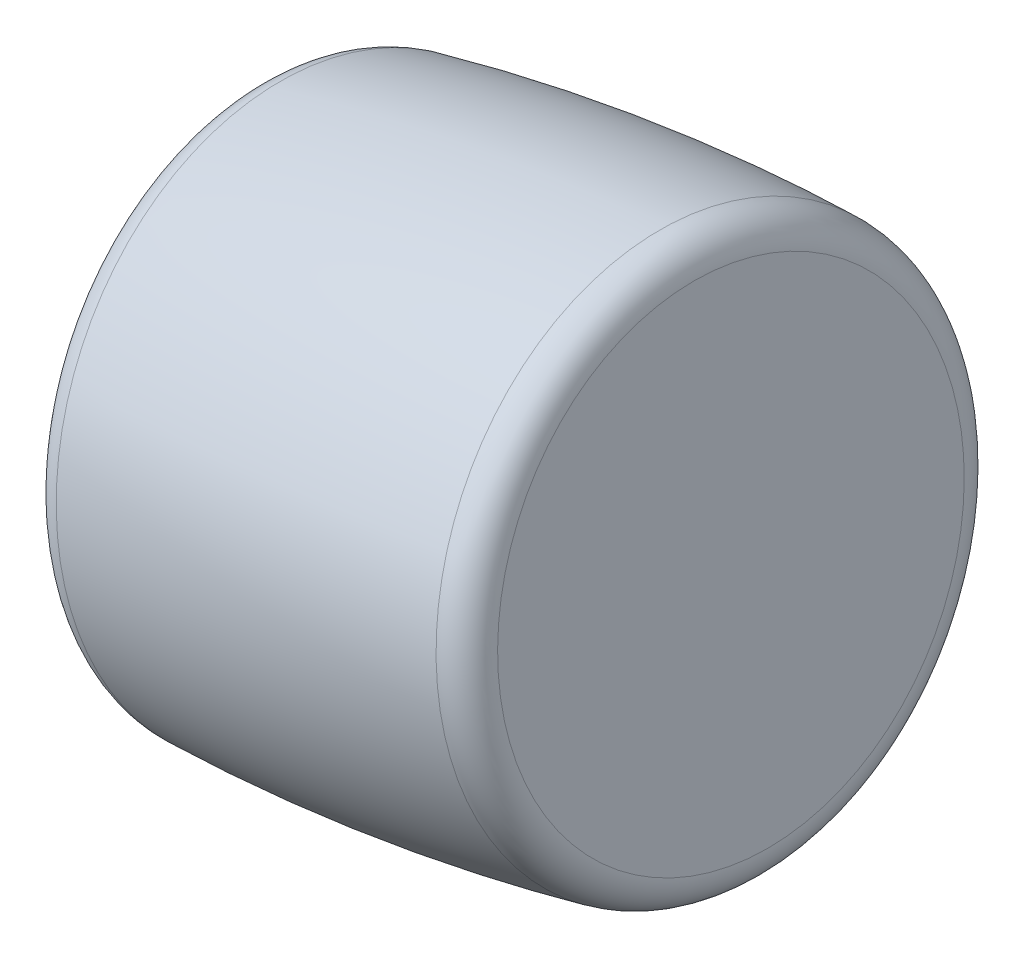
from build123d import *


with BuildPart() as part:
    # Sketch1 → Revolve1 (revolve)
    with BuildSketch(Plane.XY):
        with BuildLine():
            Line((1.915770545, 42.395566672), (1.063301222, 47.678323346))
            ThreePointArc((1.063301222, 47.678323346), (1.176472256, 48.208968761), (1.617923731, 48.524425312))
            ThreePointArc((1.617923731, 48.524425312), (5.996363051, 49.435542819), (10.439151002, 49.947891537))
            ThreePointArc((10.439151002, 49.947891537), (10.957421034, 49.787303624), (11.231760132, 49.319190003))
            Line((11.231760132, 49.319190003), (12.084229455, 44.036433328))
            Line((12.084229455, 44.036433328), (1.915770545, 42.395566672))
        make_face()
    revolve(axis=Axis((12.084229455, 44.036433328, 0), (-0.98722902, -0.159307442, 0)))


solid = part.part
